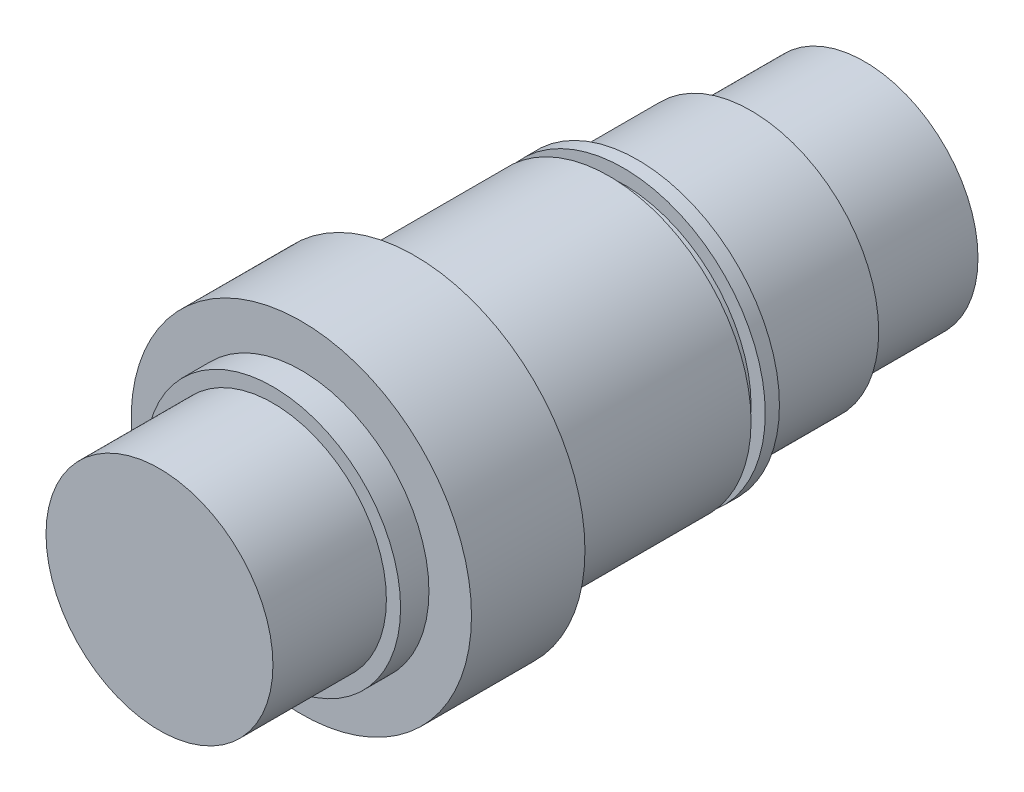
from build123d import *

# Parameters (mm, degrees)
SKETCH2_R           = 25.4
BOSS_EXTRUDE1_DEPTH = 25.4
SKETCH3_R           = 28.575
BOSS_EXTRUDE2_DEPTH = 25.4
SKETCH4_R           = 31.75
BOSS_EXTRUDE3_DEPTH = 3.175
SKETCH5_R           = 28.575
BOSS_EXTRUDE4_DEPTH = 3.175
SKETCH6_R           = 31.75
BOSS_EXTRUDE5_DEPTH = 43.5356
SKETCH7_R           = 38.1
BOSS_EXTRUDE6_DEPTH = 25.4
SKETCH8_R           = 28.575
BOSS_EXTRUDE7_DEPTH = 6.35
SKETCH9_R           = 25.4
BOSS_EXTRUDE8_DEPTH = 25.4
CUT_EXTRUDE1_DEPTH  = 3.175


with BuildPart() as part:
    # Sketch2 → Boss-Extrude1 (new body)
    with BuildSketch(Plane.XY):
        Circle(SKETCH2_R)
    extrude(amount=BOSS_EXTRUDE1_DEPTH)

    # Sketch3 → Boss-Extrude2 (add)
    with BuildSketch(Plane.XY.offset(25.4)):
        Circle(SKETCH3_R)
    extrude(amount=BOSS_EXTRUDE2_DEPTH)

    # Sketch4 → Boss-Extrude3 (add)
    with BuildSketch(Plane.XY.offset(50.8)):
        Circle(SKETCH4_R)
    extrude(amount=BOSS_EXTRUDE3_DEPTH)

    # Sketch5 → Boss-Extrude4 (add)
    with BuildSketch(Plane.XY.offset(53.975)):
        Circle(SKETCH5_R)
    extrude(amount=BOSS_EXTRUDE4_DEPTH)

    # Sketch6 → Boss-Extrude5 (add)
    with BuildSketch(Plane.XY.offset(57.15)):
        Circle(SKETCH6_R)
    extrude(amount=BOSS_EXTRUDE5_DEPTH)

    # Sketch7 → Boss-Extrude6 (add)
    with BuildSketch(Plane.XY.offset(100.6856)):
        Circle(SKETCH7_R)
    extrude(amount=BOSS_EXTRUDE6_DEPTH)

    # Sketch8 → Boss-Extrude7 (add)
    with BuildSketch(Plane.XY.offset(126.0856)):
        Circle(SKETCH8_R)
    extrude(amount=BOSS_EXTRUDE7_DEPTH)

    # Sketch9 → Boss-Extrude8 (add)
    with BuildSketch(Plane.XY.offset(132.4356)):
        Circle(SKETCH9_R)
    extrude(amount=BOSS_EXTRUDE8_DEPTH)

    # Sketch10 → Cut-Extrude1 (cut)
    with BuildSketch(Plane(origin=(0, -31.75, 0), x_dir=(-1, 0, 0), z_dir=(0, -1, 0))):
        with BuildLine():
            Line((3.175, -69.3928), (3.175, -88.4428))
            ThreePointArc((3.175, -88.4428), (0, -91.6178), (-3.175, -88.4428))
            Line((-3.175, -88.4428), (-3.175, -69.3928))
            ThreePointArc((-3.175, -69.3928), (0, -66.2178), (3.175, -69.3928))
        make_face()
    extrude(amount=-CUT_EXTRUDE1_DEPTH, mode=Mode.SUBTRACT)


solid = part.part
